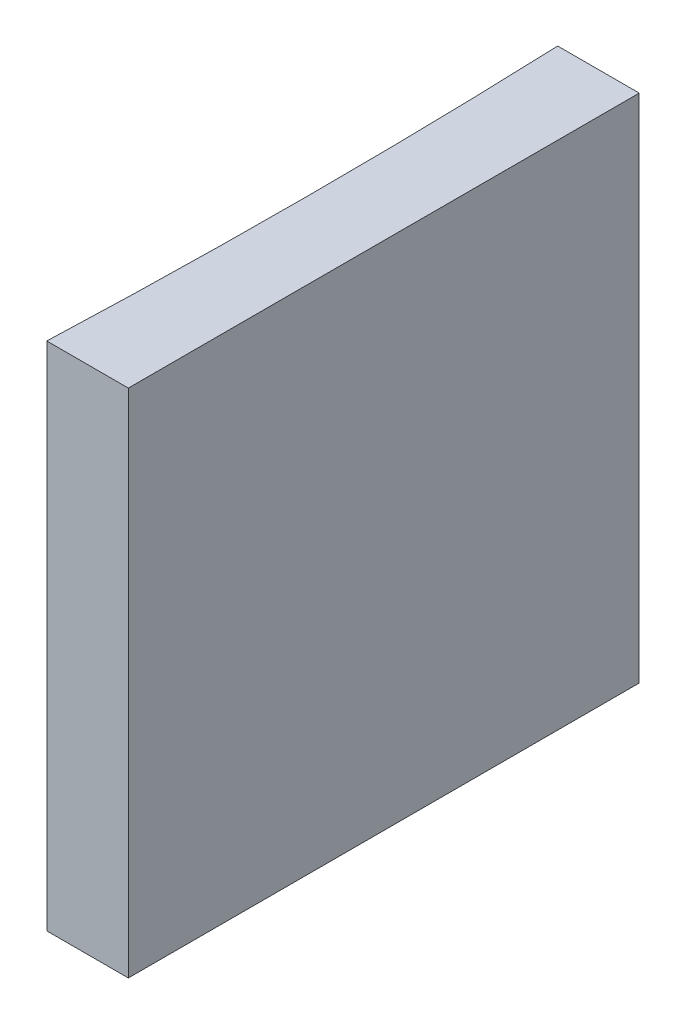
from build123d import *

# Parameters (mm, degrees)
EXTRUDE_1_DEPTH = 20


with BuildPart() as part:
    # 草图1 → 凸台-拉伸1 (new body)
    with BuildSketch(Plane(origin=(0, 0, 0), x_dir=(1, 0, 0), z_dir=(0, 1, 0))):
        with BuildLine():
            Line((0, 0), (0, -20))
            Line((0, -20), (-3.193496017, -20))
            ThreePointArc((-3.193496017, -20), (-3, -10), (-3.193496017, 0))
            Line((-3.193496017, 0), (0, 0))
        make_face()
    extrude(amount=EXTRUDE_1_DEPTH)


solid = part.part
